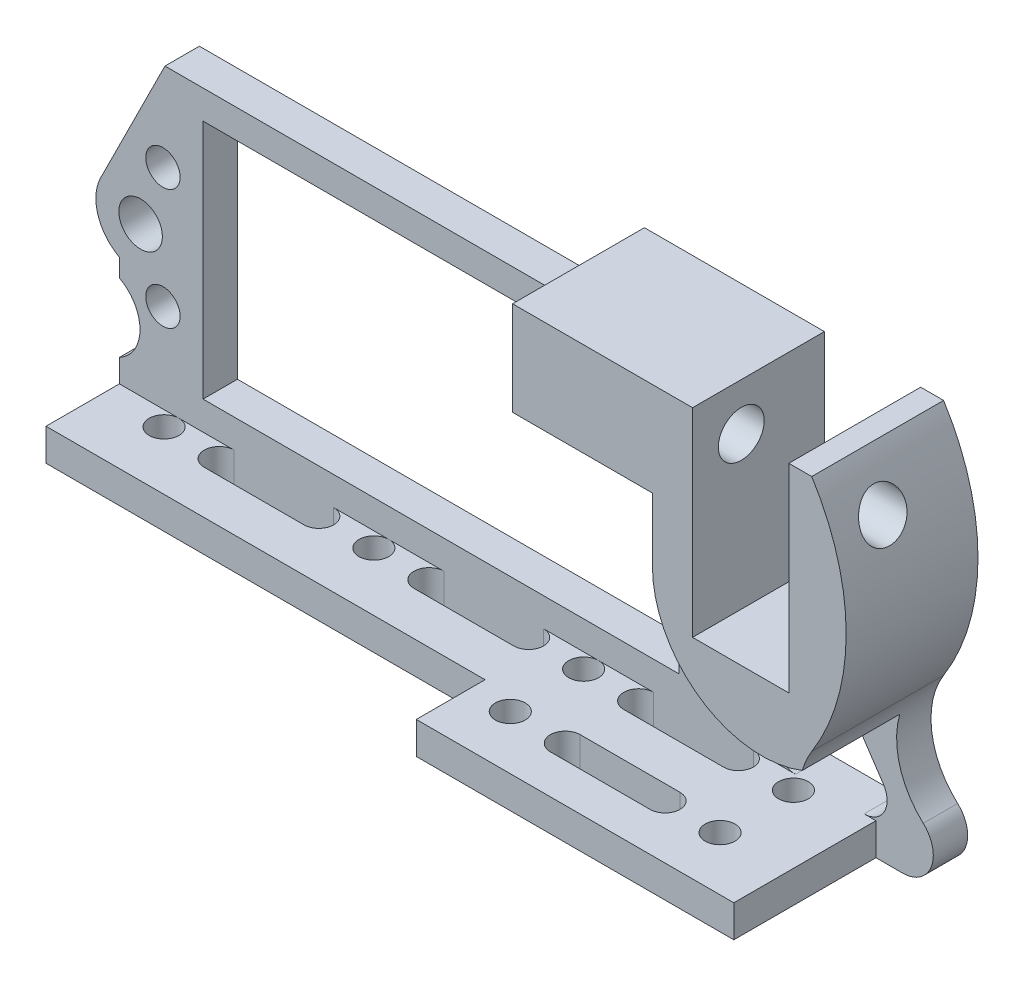
from build123d import *

# Parameters (mm, degrees)
SKETCH1_R           = 1.5
SKETCH1_R_2         = 1.9
SKETCH1_W           = 41.5
SKETCH1_H           = 21
BOSS_EXTRUDE1_DEPTH = 3
BOSS_EXTRUDE2_DEPTH = 8.5
BOSS_EXTRUDE3_DEPTH = 12.4
SKETCH4_R           = 1.3
CUT_EXTRUDE1_DEPTH  = 12.4
SKETCH5_W           = 38.3
SKETCH5_H           = 6
CUT_EXTRUDE2_DEPTH  = 12.4
SKETCH6_R           = 2
CUT_EXTRUDE3_DEPTH  = 42.4


with BuildPart() as part:
    # Sketch1 → Boss-Extrude1 (new body)
    with BuildSketch(Plane.XY):
        with BuildLine():
            Line((-3.321392505, 23.5), (33.5, 23.5))
            ThreePointArc((33.5, 23.5), (34.914213562, 24.085786438), (35.5, 25.5))
            Line((35.5, 25.5), (35.5, 29.2))
            Line((35.5, 29.2), (51.2, 29.2))
            Line((51.2, 29.2), (51.2, 11.85))
            Line((51.2, 11.85), (59.6, 11.85))
            Line((59.6, 11.85), (59.6, 29.2))
            Line((59.6, 29.2), (61.598774259, 29.2))
            ThreePointArc((61.598774259, 29.2), (64.6, 18.815792472), (61.598774259, 8.431584945))
            ThreePointArc((61.598774259, 8.431584945), (60.564280065, 3.6748318), (62.825022394, -0.636307591))
            ThreePointArc((62.825022394, -0.636307591), (63.518866569, -3.587010054), (61.018120639, -5.3))
            Line((61.018120639, -5.3), (-7.3, -5.3))
            Line((-7.3, -5.3), (-7.3, -0.5))
            ThreePointArc((-7.3, -0.5), (-5.5, 2.5), (-7.3, 5.5))
            Line((-7.3, 5.5), (-7.3, 7.067398479))
            ThreePointArc((-7.3, 7.067398479), (-9.16671437, 9.322502878), (-8.93851269, 12.241071429))
            Line((-8.93851269, 12.241071429), (-3.321392505, 23.5))
        make_face()
        with Locations((-3.5, 15.75)):
            Circle(SKETCH1_R, mode=Mode.SUBTRACT)
        with Locations((-5.448717527, 10.5)):
            Circle(SKETCH1_R_2, mode=Mode.SUBTRACT)
        with Locations((-3.5, 5.25)):
            Circle(SKETCH1_R, mode=Mode.SUBTRACT)
        with Locations((45, 5.25)):
            Circle(SKETCH1_R, mode=Mode.SUBTRACT)
        with Locations((45, 15.75)):
            Circle(SKETCH1_R, mode=Mode.SUBTRACT)
        with Locations((20.75, 10.5)):
            Rectangle(SKETCH1_W, SKETCH1_H, mode=Mode.SUBTRACT)
        with BuildLine():
            Line((49.961498231, 0.517681209), (52.768212791, 5.266104179))
            ThreePointArc((52.768212791, 5.266104179), (54.433574671, 6.247628711), (56.151588007, 5.361484945))
            Line((56.151588007, 5.361484945), (59.33232839, 0.613061975))
            ThreePointArc((59.33232839, 0.613061975), (59.435061822, -1.441773872), (57.670674684, -2.5))
            Line((57.670674684, -2.5), (51.683219741, -2.5))
            ThreePointArc((51.683219741, -2.5), (49.946072306, -1.491119968), (49.961498231, 0.517681209))
        make_face(mode=Mode.SUBTRACT)
    extrude(amount=BOSS_EXTRUDE1_DEPTH)

    # Sketch2 → Boss-Extrude2 (add)
    with BuildSketch(Plane.XY.offset(3)):
        with BuildLine():
            Line((61.598774259, 29.2), (59.6, 29.2))
            Line((59.6, 29.2), (59.6, 11.85))
            Line((59.6, 11.85), (51.2, 11.85))
            Line((51.2, 11.85), (51.2, 29.2))
            Line((51.2, 29.2), (35.5, 29.2))
            Line((35.5, 29.2), (35.5, 21))
            Line((35.5, 21), (47.7, 21))
            Line((47.7, 21), (47.7, 15.472440326))
            ThreePointArc((47.7, 15.472440326), (51.882998061, 7.567370729), (60.771830096, 6.579310435))
            ThreePointArc((60.771830096, 6.579310435), (61.119060066, 7.535021345), (61.598774259, 8.431584945))
            ThreePointArc((61.598774259, 8.431584945), (64.6, 18.815792472), (61.598774259, 29.2))
        make_face()
    extrude(amount=BOSS_EXTRUDE2_DEPTH)

    # Sketch3 → Boss-Extrude3 (add)
    with BuildSketch(Plane.XY.offset(3)):
        Polygon((46.39680607, -5.3), (-7.3, -5.3), (-7.3, -2.5), (58.7, -2.5), (58.7, -5.3), align=None)
    extrude(amount=BOSS_EXTRUDE3_DEPTH)

    # Sketch4 → Cut-Extrude1 (cut)
    with BuildSketch(Plane(origin=(0, -2.5, 0), x_dir=(1, 0, 0), z_dir=(0, 1, 0))):
        with Locations((52.8, -4.3)):
            Circle(SKETCH4_R)
        with Locations((34.5, -4.3)):
            Circle(SKETCH4_R)
        with Locations((52.8, -10.7)):
            Circle(SKETCH4_R)
        with Locations((34.5, -10.7)):
            Circle(SKETCH4_R)
        with Locations((16.2, -10.7)):
            Circle(SKETCH4_R)
        with Locations((-2.1, -10.7)):
            Circle(SKETCH4_R)
        with Locations((16.2, -4.3)):
            Circle(SKETCH4_R)
        with Locations((-2.1, -4.3)):
            Circle(SKETCH4_R)
        with BuildLine():
            Line((48, -5.6), (39.3, -5.6))
            ThreePointArc((39.3, -5.6), (38, -4.3), (39.3, -3))
            Line((39.3, -3), (48, -3))
            ThreePointArc((48, -3), (49.3, -4.3), (48, -5.6))
        make_face()
        with BuildLine():
            Line((48, -12), (39.3, -12))
            ThreePointArc((39.3, -12), (38, -10.7), (39.3, -9.4))
            Line((39.3, -9.4), (48, -9.4))
            ThreePointArc((48, -9.4), (49.3, -10.7), (48, -12))
        make_face()
        with BuildLine():
            Line((29.7, -12), (21, -12))
            ThreePointArc((21, -12), (19.7, -10.7), (21, -9.4))
            Line((21, -9.4), (29.7, -9.4))
            ThreePointArc((29.7, -9.4), (31, -10.7), (29.7, -12))
        make_face()
        with BuildLine():
            Line((11.4, -12), (2.7, -12))
            ThreePointArc((2.7, -12), (1.4, -10.7), (2.7, -9.4))
            Line((2.7, -9.4), (11.4, -9.4))
            ThreePointArc((11.4, -9.4), (12.7, -10.7), (11.4, -12))
        make_face()
        with BuildLine():
            Line((29.7, -5.6), (21, -5.6))
            ThreePointArc((21, -5.6), (19.7, -4.3), (21, -3))
            Line((21, -3), (29.7, -3))
            ThreePointArc((29.7, -3), (31, -4.3), (29.7, -5.6))
        make_face()
        with BuildLine():
            Line((11.4, -5.6), (2.7, -5.6))
            ThreePointArc((2.7, -5.6), (1.4, -4.3), (2.7, -3))
            Line((2.7, -3), (11.4, -3))
            ThreePointArc((11.4, -3), (12.7, -4.3), (11.4, -5.6))
        make_face()
    extrude(amount=-CUT_EXTRUDE1_DEPTH, mode=Mode.SUBTRACT)

    # Sketch5 → Cut-Extrude2 (cut)
    with BuildSketch(Plane(origin=(0, -2.5, 0), x_dir=(1, 0, 0), z_dir=(0, 1, 0))):
        with Locations((11.85, -12.4)):
            Rectangle(SKETCH5_W, SKETCH5_H)
    extrude(amount=-CUT_EXTRUDE2_DEPTH, mode=Mode.SUBTRACT)

    # Sketch6 → Cut-Extrude3 (cut)
    with BuildSketch(Plane.ZY.offset(-35.5)):
        with Locations((7.25, 25.1)):
            Circle(SKETCH6_R)
    extrude(amount=-CUT_EXTRUDE3_DEPTH, mode=Mode.SUBTRACT)


solid = part.part
